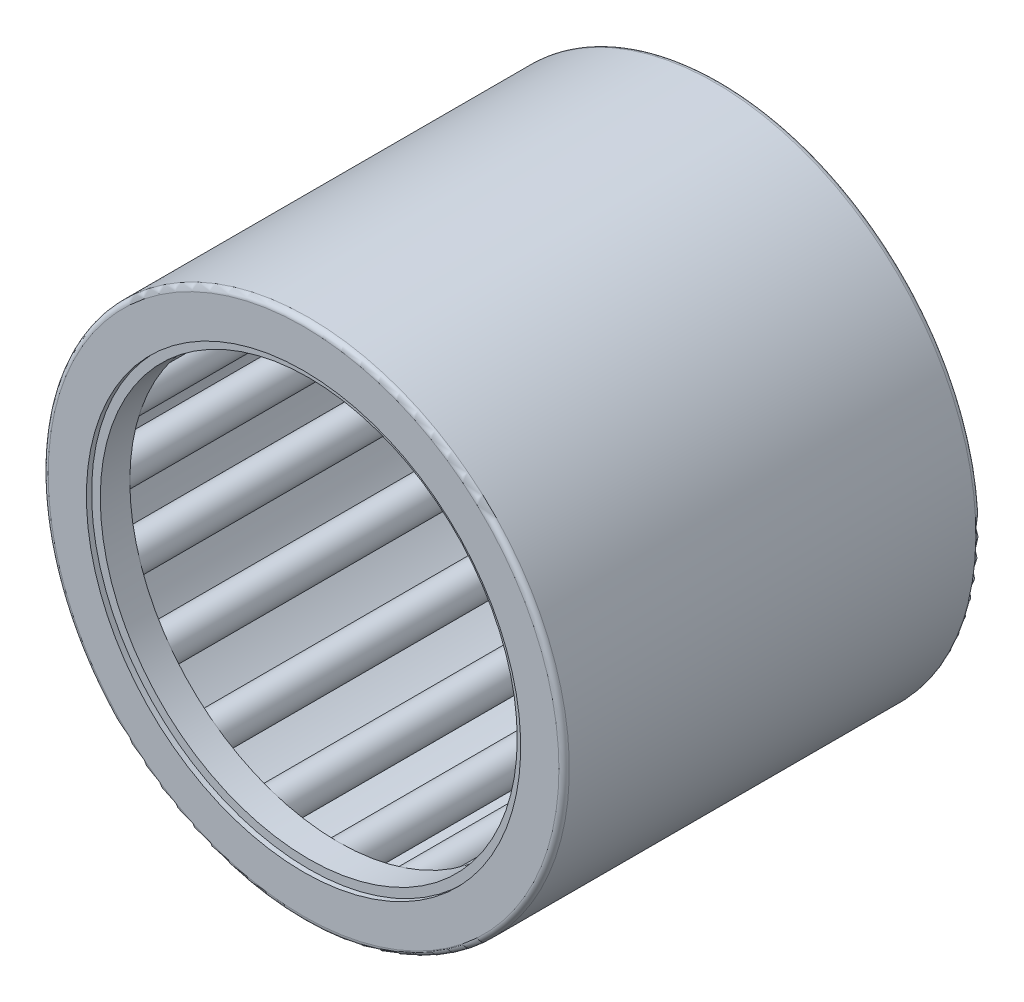
from build123d import *

# Parameters (mm, degrees)
SKETCH2_W         = 21.166666666
SKETCH2_H         = 0.79375
SKETCH3_W         = 23.283333334
SKETCH3_H         = 0.264583334
CIRPATTERN1_COUNT = 20
CIRPATTERN1_ANGLE = 342
FILLET1_R         = 0.3175
SKETCH4_W         = 1.799166667
SKETCH4_H         = 0.529166667
SKETCH5_W         = 1.799166667
SKETCH5_H         = 0.529166667


with BuildPart() as part:
    # Sketch1 → Revolve1 (revolve)
    with BuildSketch(Plane(origin=(0, 0, 0), x_dir=(0, 0, -1), z_dir=(1, 0, 0))):
        Polygon((-12.7, 15.875), (12.7, 15.875), (12.7, 13.229166667), (11.641666667, 13.229166667), (11.641666667, 14.816666667), (-11.641666667, 14.816666667), (-11.641666667, 13.229166667), (-12.7, 13.229166667), align=None)
    revolve(axis=Axis((0, 0, 12.7), (0, 0, -1)))

    # Fillet1
    fillet1_edges = [part.edges().sort_by_distance(p)[0] for p in [
        (0, -15.875, 12.7),
        (0, -15.875, -12.7),
    ]]
    fillet(fillet1_edges, radius=FILLET1_R)


with BuildPart() as body_2:
    # Sketch2 → Revolve2 (revolve)
    with BuildSketch(Plane(origin=(0, 0, 0), x_dir=(0, 0, -1), z_dir=(1, 0, 0))):
        with Locations((0, 14.419791667)):
            Rectangle(SKETCH2_W, SKETCH2_H)
    revolve(axis=Axis((0, 13.758333333, 10.583333333), (0, 0, -1)))


with BuildPart() as body_3:
    # Sketch3 → Revolve3 (revolve)
    with BuildSketch(Plane(origin=(0, 0, 0), x_dir=(0, 0, -1), z_dir=(1, 0, 0))):
        with Locations((0, 13.890625)):
            Rectangle(SKETCH3_W, SKETCH3_H)
    revolve(axis=Axis((0, 13.758333333, 11.641666667), (0, 0, -1)))


with BuildPart() as cirpattern1_1:
    # CirPattern1: pattern copy
    add(body_2.part.rotate(Axis((0, 0, -12.7), (0, 0, 1)), 1 * CIRPATTERN1_ANGLE / (CIRPATTERN1_COUNT - 1)))


with BuildPart() as cirpattern1_2:
    # CirPattern1: pattern copy
    add(body_2.part.rotate(Axis((0, 0, -12.7), (0, 0, 1)), 2 * CIRPATTERN1_ANGLE / (CIRPATTERN1_COUNT - 1)))


with BuildPart() as cirpattern1_3:
    # CirPattern1: pattern copy
    add(body_2.part.rotate(Axis((0, 0, -12.7), (0, 0, 1)), 3 * CIRPATTERN1_ANGLE / (CIRPATTERN1_COUNT - 1)))


with BuildPart() as cirpattern1_4:
    # CirPattern1: pattern copy
    add(body_2.part.rotate(Axis((0, 0, -12.7), (0, 0, 1)), 4 * CIRPATTERN1_ANGLE / (CIRPATTERN1_COUNT - 1)))


with BuildPart() as cirpattern1_5:
    # CirPattern1: pattern copy
    add(body_2.part.rotate(Axis((0, 0, -12.7), (0, 0, 1)), 5 * CIRPATTERN1_ANGLE / (CIRPATTERN1_COUNT - 1)))


with BuildPart() as cirpattern1_6:
    # CirPattern1: pattern copy
    add(body_2.part.rotate(Axis((0, 0, -12.7), (0, 0, 1)), 6 * CIRPATTERN1_ANGLE / (CIRPATTERN1_COUNT - 1)))


with BuildPart() as cirpattern1_7:
    # CirPattern1: pattern copy
    add(body_2.part.rotate(Axis((0, 0, -12.7), (0, 0, 1)), 7 * CIRPATTERN1_ANGLE / (CIRPATTERN1_COUNT - 1)))


with BuildPart() as cirpattern1_8:
    # CirPattern1: pattern copy
    add(body_2.part.rotate(Axis((0, 0, -12.7), (0, 0, 1)), 8 * CIRPATTERN1_ANGLE / (CIRPATTERN1_COUNT - 1)))


with BuildPart() as cirpattern1_9:
    # CirPattern1: pattern copy
    add(body_2.part.rotate(Axis((0, 0, -12.7), (0, 0, 1)), 9 * CIRPATTERN1_ANGLE / (CIRPATTERN1_COUNT - 1)))


with BuildPart() as cirpattern1_10:
    # CirPattern1: pattern copy
    add(body_2.part.rotate(Axis((0, 0, -12.7), (0, 0, 1)), 10 * CIRPATTERN1_ANGLE / (CIRPATTERN1_COUNT - 1)))


with BuildPart() as cirpattern1_11:
    # CirPattern1: pattern copy
    add(body_2.part.rotate(Axis((0, 0, -12.7), (0, 0, 1)), 11 * CIRPATTERN1_ANGLE / (CIRPATTERN1_COUNT - 1)))


with BuildPart() as cirpattern1_12:
    # CirPattern1: pattern copy
    add(body_2.part.rotate(Axis((0, 0, -12.7), (0, 0, 1)), 12 * CIRPATTERN1_ANGLE / (CIRPATTERN1_COUNT - 1)))


with BuildPart() as cirpattern1_13:
    # CirPattern1: pattern copy
    add(body_2.part.rotate(Axis((0, 0, -12.7), (0, 0, 1)), 13 * CIRPATTERN1_ANGLE / (CIRPATTERN1_COUNT - 1)))


with BuildPart() as cirpattern1_14:
    # CirPattern1: pattern copy
    add(body_2.part.rotate(Axis((0, 0, -12.7), (0, 0, 1)), 14 * CIRPATTERN1_ANGLE / (CIRPATTERN1_COUNT - 1)))


with BuildPart() as cirpattern1_15:
    # CirPattern1: pattern copy
    add(body_2.part.rotate(Axis((0, 0, -12.7), (0, 0, 1)), 15 * CIRPATTERN1_ANGLE / (CIRPATTERN1_COUNT - 1)))


with BuildPart() as cirpattern1_16:
    # CirPattern1: pattern copy
    add(body_2.part.rotate(Axis((0, 0, -12.7), (0, 0, 1)), 16 * CIRPATTERN1_ANGLE / (CIRPATTERN1_COUNT - 1)))


with BuildPart() as cirpattern1_17:
    # CirPattern1: pattern copy
    add(body_2.part.rotate(Axis((0, 0, -12.7), (0, 0, 1)), 17 * CIRPATTERN1_ANGLE / (CIRPATTERN1_COUNT - 1)))


with BuildPart() as cirpattern1_18:
    # CirPattern1: pattern copy
    add(body_2.part.rotate(Axis((0, 0, -12.7), (0, 0, 1)), 18 * CIRPATTERN1_ANGLE / (CIRPATTERN1_COUNT - 1)))


with BuildPart() as cirpattern1_19:
    # CirPattern1: pattern copy
    add(body_2.part.rotate(Axis((0, 0, -12.7), (0, 0, 1)), 19 * CIRPATTERN1_ANGLE / (CIRPATTERN1_COUNT - 1)))


with BuildPart() as cirpattern1_20:
    # CirPattern1: pattern copy
    add(body_3.part.rotate(Axis((0, 0, -12.7), (0, 0, 1)), 1 * CIRPATTERN1_ANGLE / (CIRPATTERN1_COUNT - 1)))


with BuildPart() as cirpattern1_21:
    # CirPattern1: pattern copy
    add(body_3.part.rotate(Axis((0, 0, -12.7), (0, 0, 1)), 2 * CIRPATTERN1_ANGLE / (CIRPATTERN1_COUNT - 1)))


with BuildPart() as cirpattern1_22:
    # CirPattern1: pattern copy
    add(body_3.part.rotate(Axis((0, 0, -12.7), (0, 0, 1)), 3 * CIRPATTERN1_ANGLE / (CIRPATTERN1_COUNT - 1)))


with BuildPart() as cirpattern1_23:
    # CirPattern1: pattern copy
    add(body_3.part.rotate(Axis((0, 0, -12.7), (0, 0, 1)), 4 * CIRPATTERN1_ANGLE / (CIRPATTERN1_COUNT - 1)))


with BuildPart() as cirpattern1_24:
    # CirPattern1: pattern copy
    add(body_3.part.rotate(Axis((0, 0, -12.7), (0, 0, 1)), 5 * CIRPATTERN1_ANGLE / (CIRPATTERN1_COUNT - 1)))


with BuildPart() as cirpattern1_25:
    # CirPattern1: pattern copy
    add(body_3.part.rotate(Axis((0, 0, -12.7), (0, 0, 1)), 6 * CIRPATTERN1_ANGLE / (CIRPATTERN1_COUNT - 1)))


with BuildPart() as cirpattern1_26:
    # CirPattern1: pattern copy
    add(body_3.part.rotate(Axis((0, 0, -12.7), (0, 0, 1)), 7 * CIRPATTERN1_ANGLE / (CIRPATTERN1_COUNT - 1)))


with BuildPart() as cirpattern1_27:
    # CirPattern1: pattern copy
    add(body_3.part.rotate(Axis((0, 0, -12.7), (0, 0, 1)), 8 * CIRPATTERN1_ANGLE / (CIRPATTERN1_COUNT - 1)))


with BuildPart() as cirpattern1_28:
    # CirPattern1: pattern copy
    add(body_3.part.rotate(Axis((0, 0, -12.7), (0, 0, 1)), 9 * CIRPATTERN1_ANGLE / (CIRPATTERN1_COUNT - 1)))


with BuildPart() as cirpattern1_29:
    # CirPattern1: pattern copy
    add(body_3.part.rotate(Axis((0, 0, -12.7), (0, 0, 1)), 10 * CIRPATTERN1_ANGLE / (CIRPATTERN1_COUNT - 1)))


with BuildPart() as cirpattern1_30:
    # CirPattern1: pattern copy
    add(body_3.part.rotate(Axis((0, 0, -12.7), (0, 0, 1)), 11 * CIRPATTERN1_ANGLE / (CIRPATTERN1_COUNT - 1)))


with BuildPart() as cirpattern1_31:
    # CirPattern1: pattern copy
    add(body_3.part.rotate(Axis((0, 0, -12.7), (0, 0, 1)), 12 * CIRPATTERN1_ANGLE / (CIRPATTERN1_COUNT - 1)))


with BuildPart() as cirpattern1_32:
    # CirPattern1: pattern copy
    add(body_3.part.rotate(Axis((0, 0, -12.7), (0, 0, 1)), 13 * CIRPATTERN1_ANGLE / (CIRPATTERN1_COUNT - 1)))


with BuildPart() as cirpattern1_33:
    # CirPattern1: pattern copy
    add(body_3.part.rotate(Axis((0, 0, -12.7), (0, 0, 1)), 14 * CIRPATTERN1_ANGLE / (CIRPATTERN1_COUNT - 1)))


with BuildPart() as cirpattern1_34:
    # CirPattern1: pattern copy
    add(body_3.part.rotate(Axis((0, 0, -12.7), (0, 0, 1)), 15 * CIRPATTERN1_ANGLE / (CIRPATTERN1_COUNT - 1)))


with BuildPart() as cirpattern1_35:
    # CirPattern1: pattern copy
    add(body_3.part.rotate(Axis((0, 0, -12.7), (0, 0, 1)), 16 * CIRPATTERN1_ANGLE / (CIRPATTERN1_COUNT - 1)))


with BuildPart() as cirpattern1_36:
    # CirPattern1: pattern copy
    add(body_3.part.rotate(Axis((0, 0, -12.7), (0, 0, 1)), 17 * CIRPATTERN1_ANGLE / (CIRPATTERN1_COUNT - 1)))


with BuildPart() as cirpattern1_37:
    # CirPattern1: pattern copy
    add(body_3.part.rotate(Axis((0, 0, -12.7), (0, 0, 1)), 18 * CIRPATTERN1_ANGLE / (CIRPATTERN1_COUNT - 1)))


with BuildPart() as cirpattern1_38:
    # CirPattern1: pattern copy
    add(body_3.part.rotate(Axis((0, 0, -12.7), (0, 0, 1)), 19 * CIRPATTERN1_ANGLE / (CIRPATTERN1_COUNT - 1)))


with BuildPart() as body_42:
    # Sketch4 → Revolve4 (revolve)
    with BuildSketch(Plane(origin=(0, 0, 0), x_dir=(0, 0, -1), z_dir=(1, 0, 0))):
        with Locations((11.482916666, 12.964583334)):
            Rectangle(SKETCH4_W, SKETCH4_H)
    revolve(axis=Axis((0, 0, 12.7), (0, 0, -1)))


with BuildPart() as body_43:
    # Sketch5 → Revolve5 (revolve)
    with BuildSketch(Plane(origin=(0, 0, 0), x_dir=(0, 0, -1), z_dir=(1, 0, 0))):
        with Locations((-11.482916666, 12.964583334)):
            Rectangle(SKETCH5_W, SKETCH5_H)
    revolve(axis=Axis((0, 0, 12.7), (0, 0, -1)))


solid = Compound([part.part, body_2.part, body_3.part, cirpattern1_1.part, cirpattern1_2.part, cirpattern1_3.part, cirpattern1_4.part, cirpattern1_5.part, cirpattern1_6.part, cirpattern1_7.part, cirpattern1_8.part, cirpattern1_9.part, cirpattern1_10.part, cirpattern1_11.part, cirpattern1_12.part, cirpattern1_13.part, cirpattern1_14.part, cirpattern1_15.part, cirpattern1_16.part, cirpattern1_17.part, cirpattern1_18.part, cirpattern1_19.part, cirpattern1_20.part, cirpattern1_21.part, cirpattern1_22.part, cirpattern1_23.part, cirpattern1_24.part, cirpattern1_25.part, cirpattern1_26.part, cirpattern1_27.part, cirpattern1_28.part, cirpattern1_29.part, cirpattern1_30.part, cirpattern1_31.part, cirpattern1_32.part, cirpattern1_33.part, cirpattern1_34.part, cirpattern1_35.part, cirpattern1_36.part, cirpattern1_37.part, cirpattern1_38.part, body_42.part, body_43.part])
